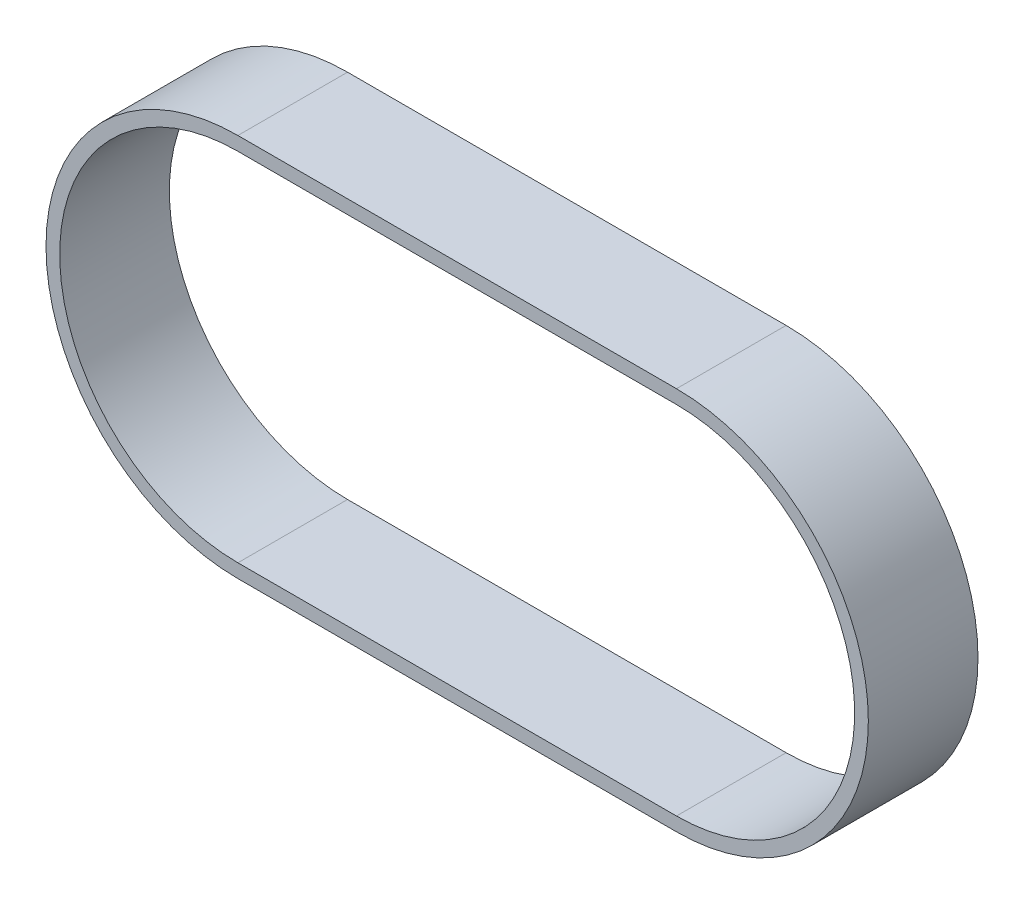
from build123d import *

# Parameters (mm, degrees)
BOSS_EXTRU_1_DEPTH = 20


with BuildPart() as part:
    # Esquisse1 → Boss.-Extru.1 (new body)
    with BuildSketch(Plane.XY):
        with BuildLine():
            Line((0, 35), (80, 35))
            ThreePointArc((80, 35), (115, 0), (80, -35))
            Line((80, -35), (0, -35))
            ThreePointArc((0, -35), (-35, 0), (0, 35))
        make_face()
        with BuildLine():
            Line((0, 32.5), (80, 32.5))
            ThreePointArc((80, 32.5), (112.5, 0), (80, -32.5))
            Line((80, -32.5), (0, -32.5))
            ThreePointArc((0, -32.5), (-32.5, 0), (0, 32.5))
        make_face(mode=Mode.SUBTRACT)
    extrude(amount=BOSS_EXTRU_1_DEPTH)


solid = part.part
